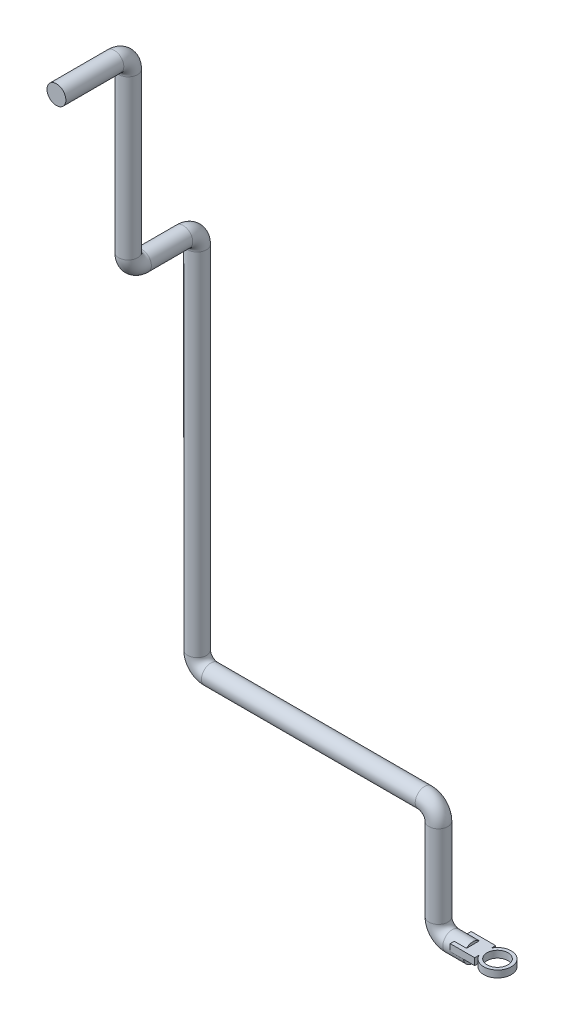
from build123d import *

# Parameters (mm, degrees)
CROQUIS1_R              = 13.7
CROQUIS2_R              = 19.995357147
CROQUIS2_R_2            = 15.215534834
SALIENTE_EXTRUIR1_DEPTH = 10


with BuildPart() as part:
    # Barrer1: sweep along a curve in space
    with BuildLine() as barrer1_path:
        Line((0, 0, 0), (-30, 0, 0))
        ThreePointArc((-30, 0, 0), (-44.142135624, 5.857864376, 0), (-50, 20, 0))
        Line((-50, 20, 0), (-50, 140, 0))
        ThreePointArc((-50, 140, 0), (-55.857864376, 154.142135624, 0), (-70, 160, 0))
        Line((-70, 160, 0), (-380, 160, 0))
        ThreePointArc((-380, 160, 0), (-394.142135624, 165.857864376, 0), (-400, 180, 0))
        Line((-400, 180, 0), (-400, 689.4, 0))
        ThreePointArc((-400, 689.4, 0), (-400, 703.542135624, 5.857864376), (-400, 709.4, 20))
        Line((-400, 709.4, 20), (-400, 709.4, 80))
        ThreePointArc((-400, 709.4, 80), (-400, 715.257864376, 94.142135624), (-400, 729.4, 100))
        Line((-400, 729.4, 100), (-400, 959.4, 100))
        ThreePointArc((-400, 959.4, 100), (-400, 973.542135624, 105.857864376), (-400, 979.4, 120))
        Line((-400, 979.4, 120), (-400, 979.4, 204))
    # Croquis1 → Barrer1 (sweep)
    with BuildSketch(Plane(origin=(0, 0, 0), x_dir=(0, 0, -1), z_dir=(1, 0, 0))):
        Circle(CROQUIS1_R)
    sweep(path=barrer1_path.line)

    # Croquis2 → Saliente-Extruir1 (add)
    with BuildSketch(Plane(origin=(0, 0, 0), x_dir=(1, 0, 0), z_dir=(0, 1, 0))):
        with BuildLine():
            Line((17.743007843, -15.215534834), (17.743007843, -8.856143388))
            ThreePointArc((17.743007843, -8.856143388), (15.67480975, 0), (17.743007843, 8.856143388))
            Line((17.743007843, 8.856143388), (17.743007843, 15.215534834))
            Line((17.743007843, 15.215534834), (-17.743007843, 15.215534834))
            Line((-17.743007843, 15.215534834), (-17.743007843, -15.215534834))
            Line((-17.743007843, -15.215534834), (17.743007843, -15.215534834))
        make_face()
        with Locations((35.670166897, 0)):
            Circle(CROQUIS2_R)
        with Locations((35.670166897, 0)):
            Circle(CROQUIS2_R_2, mode=Mode.SUBTRACT)
    extrude(amount=SALIENTE_EXTRUIR1_DEPTH)


solid = part.part
